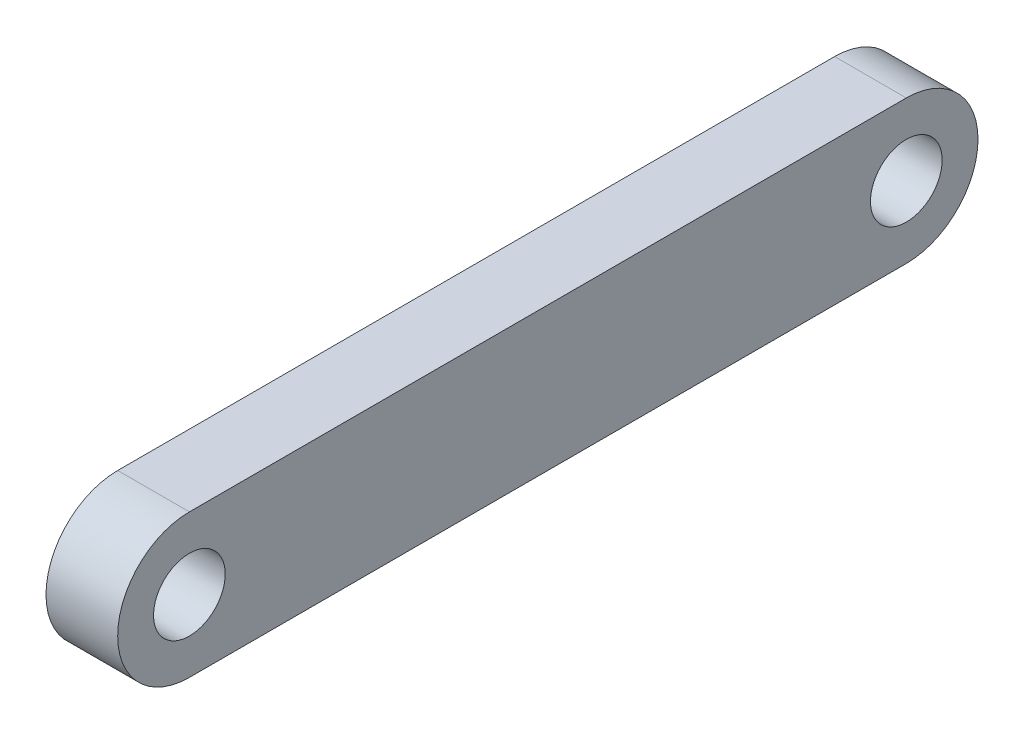
from build123d import *

# Parameters (mm, degrees)
SKETCH_1_R      = 4
EXTRUDE_1_DEPTH = 8


with BuildPart() as part:
    # 草图1 → 凸台-拉伸1 (new body)
    with BuildSketch(Plane(origin=(0, 0, 0), x_dir=(0, 0, -1), z_dir=(1, 0, 0))):
        with BuildLine():
            Line((-40, 8), (40, 8))
            ThreePointArc((40, 8), (48, 0), (40, -8))
            Line((40, -8), (-40, -8))
            ThreePointArc((-40, -8), (-48, 0), (-40, 8))
        make_face()
        with Locations((40, 0)):
            Circle(SKETCH_1_R, mode=Mode.SUBTRACT)
        with Locations((-40, 0)):
            Circle(SKETCH_1_R, mode=Mode.SUBTRACT)
    extrude(amount=EXTRUDE_1_DEPTH)


solid = part.part
